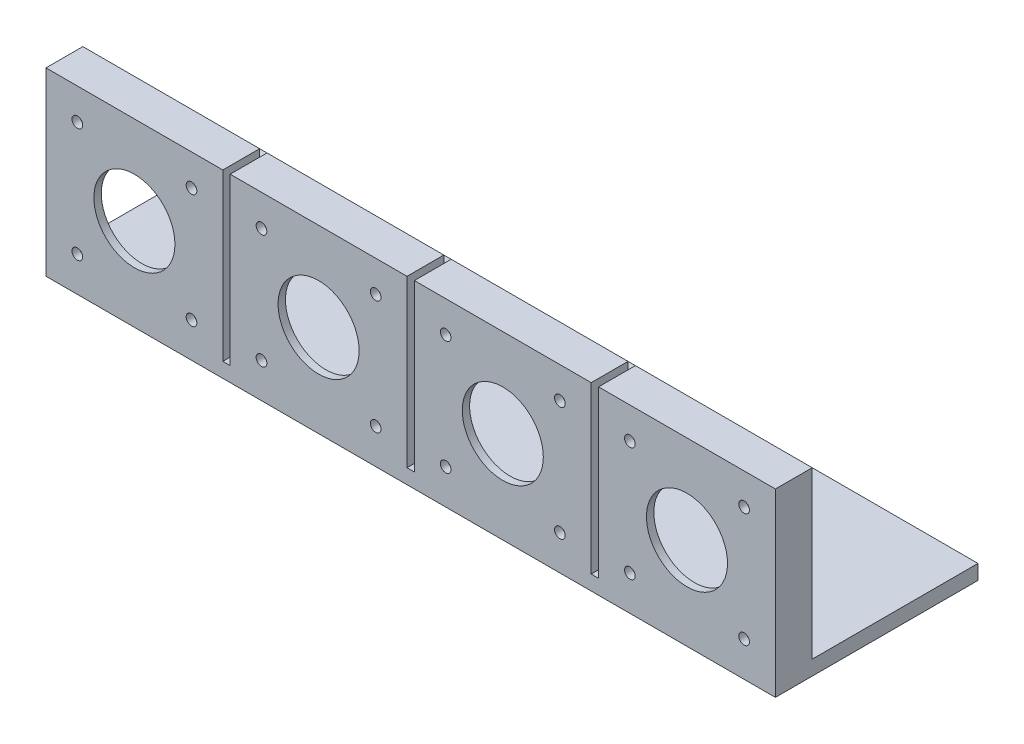
from build123d import *

# Parameters (mm, degrees)
SKETCH_1_W           = 48
SKETCH_1_H           = 48
SKETCH_1_W_2         = 42
SKETCH_1_H_2         = 42
EXTRUDE_1_DEPTH      = 10
EXTRUDE_1_2_DEPTH    = 10
EXTRUDE_1_3_DEPTH    = 10
EXTRUDE_1_4_DEPTH    = 10
SKETCH_2_W           = 42
SKETCH_2_H           = 42
SKETCH_2_R           = 1.45
SKETCH_2_R_2         = 11
EXTRUDE_2_DEPTH      = 2
EXTRUDE_3_DEPTH      = 1
EXTRUDE_3_DEPTH_BACK = 3
SKETCH_3_W           = 198
SKETCH_3_H           = 55


with BuildPart() as part:
    # Эскиз1 → Бобышка-Вытянуть1 (new body)
    with BuildSketch(Plane.XY):
        Rectangle(SKETCH_1_W, SKETCH_1_H)
        Rectangle(SKETCH_1_W_2, SKETCH_1_H_2, mode=Mode.SUBTRACT)
    extrude(amount=EXTRUDE_1_DEPTH)

    # Эскиз2 → Бобышка-Вытянуть2 (add)
    # profile 1 of 4: a face of its own
    with BuildSketch(Plane.XY.offset(10)):
        Rectangle(SKETCH_2_W, SKETCH_2_H)
        with Locations((-15.5, 15.5)):
            Circle(SKETCH_2_R, mode=Mode.SUBTRACT)
        with Locations((15.5, 15.5)):
            Circle(SKETCH_2_R, mode=Mode.SUBTRACT)
        with Locations((15.5, -15.5)):
            Circle(SKETCH_2_R, mode=Mode.SUBTRACT)
        with Locations((-15.5, -15.5)):
            Circle(SKETCH_2_R, mode=Mode.SUBTRACT)
        Circle(SKETCH_2_R_2, mode=Mode.SUBTRACT)
    # profile 2 of 4: a face of its own
    with BuildSketch(Plane.XY.offset(10)):
        with Locations((50, 0)):
            Rectangle(SKETCH_2_W, SKETCH_2_H)
        with Locations((34.5, 15.5)):
            Circle(SKETCH_2_R, mode=Mode.SUBTRACT)
        with Locations((65.5, 15.5)):
            Circle(SKETCH_2_R, mode=Mode.SUBTRACT)
        with Locations((65.5, -15.5)):
            Circle(SKETCH_2_R, mode=Mode.SUBTRACT)
        with Locations((34.5, -15.5)):
            Circle(SKETCH_2_R, mode=Mode.SUBTRACT)
        with Locations((50, 0)):
            Circle(SKETCH_2_R_2, mode=Mode.SUBTRACT)
    # profile 3 of 4: a face of its own
    with BuildSketch(Plane.XY.offset(10)):
        with Locations((100, 0)):
            Rectangle(SKETCH_2_W, SKETCH_2_H)
        with Locations((84.5, 15.5)):
            Circle(SKETCH_2_R, mode=Mode.SUBTRACT)
        with Locations((115.5, 15.5)):
            Circle(SKETCH_2_R, mode=Mode.SUBTRACT)
        with Locations((115.5, -15.5)):
            Circle(SKETCH_2_R, mode=Mode.SUBTRACT)
        with Locations((84.5, -15.5)):
            Circle(SKETCH_2_R, mode=Mode.SUBTRACT)
        with Locations((100, 0)):
            Circle(SKETCH_2_R_2, mode=Mode.SUBTRACT)
    # profile 4 of 4: a face of its own
    with BuildSketch(Plane.XY.offset(10)):
        with Locations((150, 0)):
            Rectangle(SKETCH_2_W, SKETCH_2_H)
        with Locations((134.5, 15.5)):
            Circle(SKETCH_2_R, mode=Mode.SUBTRACT)
        with Locations((165.5, 15.5)):
            Circle(SKETCH_2_R, mode=Mode.SUBTRACT)
        with Locations((165.5, -15.5)):
            Circle(SKETCH_2_R, mode=Mode.SUBTRACT)
        with Locations((134.5, -15.5)):
            Circle(SKETCH_2_R, mode=Mode.SUBTRACT)
        with Locations((150, 0)):
            Circle(SKETCH_2_R_2, mode=Mode.SUBTRACT)
    extrude(amount=-EXTRUDE_2_DEPTH)


with BuildPart() as body_2:
    # Эскиз1 → Extrude 1 2 (new body)
    with BuildSketch(Plane.XY):
        with Locations((50, 0)):
            Rectangle(SKETCH_1_W, SKETCH_1_H)
        with Locations((50, 0)):
            Rectangle(SKETCH_1_W_2, SKETCH_1_H_2, mode=Mode.SUBTRACT)
    extrude(amount=EXTRUDE_1_2_DEPTH)


with BuildPart() as body_3:
    # Эскиз1 → Extrude 1 3 (new body)
    with BuildSketch(Plane.XY):
        with Locations((100, 0)):
            Rectangle(SKETCH_1_W, SKETCH_1_H)
        with Locations((100, 0)):
            Rectangle(SKETCH_1_W_2, SKETCH_1_H_2, mode=Mode.SUBTRACT)
    extrude(amount=EXTRUDE_1_3_DEPTH)


with BuildPart() as body_4:
    # Эскиз1 → Extrude 1 4 (new body)
    with BuildSketch(Plane.XY):
        with Locations((150, 0)):
            Rectangle(SKETCH_1_W, SKETCH_1_H)
        with Locations((150, 0)):
            Rectangle(SKETCH_1_W_2, SKETCH_1_H_2, mode=Mode.SUBTRACT)
    extrude(amount=EXTRUDE_1_4_DEPTH)


with BuildPart() as extrude_2_piece_1:
    # of the separate pieces the step leaves, piece 1, a body of its own (extrude_2_pieces)
    add(part.part.solids().sort_by_distance((-24, -24, 0))[0])

    # Эскиз3 → Бобышка-Вытянуть3 (add, two sides: drawn at the far end of the back side and taken through both)
    with BuildSketch(Plane.XZ.offset(24).offset(-EXTRUDE_3_DEPTH_BACK)):
        with Locations((75, -17.5)):
            Rectangle(SKETCH_3_W, SKETCH_3_H)
    extrude(amount=EXTRUDE_3_DEPTH + EXTRUDE_3_DEPTH_BACK)


with BuildPart() as extrude_2_piece_2:
    # of the separate pieces the step leaves, piece 2, a body of its own (extrude_2_pieces)
    add(part.part.solids().sort_by_distance((79, 21, 10))[0])


with BuildPart() as extrude_2_piece_3:
    # of the separate pieces the step leaves, piece 3, a body of its own (extrude_2_pieces)
    add(part.part.solids().sort_by_distance((29, 21, 10))[0])


with BuildPart() as extrude_2_piece_4:
    # of the separate pieces the step leaves, piece 4, a body of its own (extrude_2_pieces)
    add(part.part.solids().sort_by_distance((129, 21, 10))[0])


with BuildPart() as body_4_1:
    add(body_4.part)

    # Combine 1: union Бобышка-Вытянуть2 piece 3, Бобышка-Вытянуть2 piece 2, Бобышка-Вытянуть2 piece 4, Бобышка-Вытянуть2 piece 1, body 3, body 2
    add(extrude_2_piece_3.part)
    add(extrude_2_piece_2.part)
    add(extrude_2_piece_4.part)
    add(extrude_2_piece_1.part)
    add(body_3.part)
    add(body_2.part)


solid = body_4_1.part
